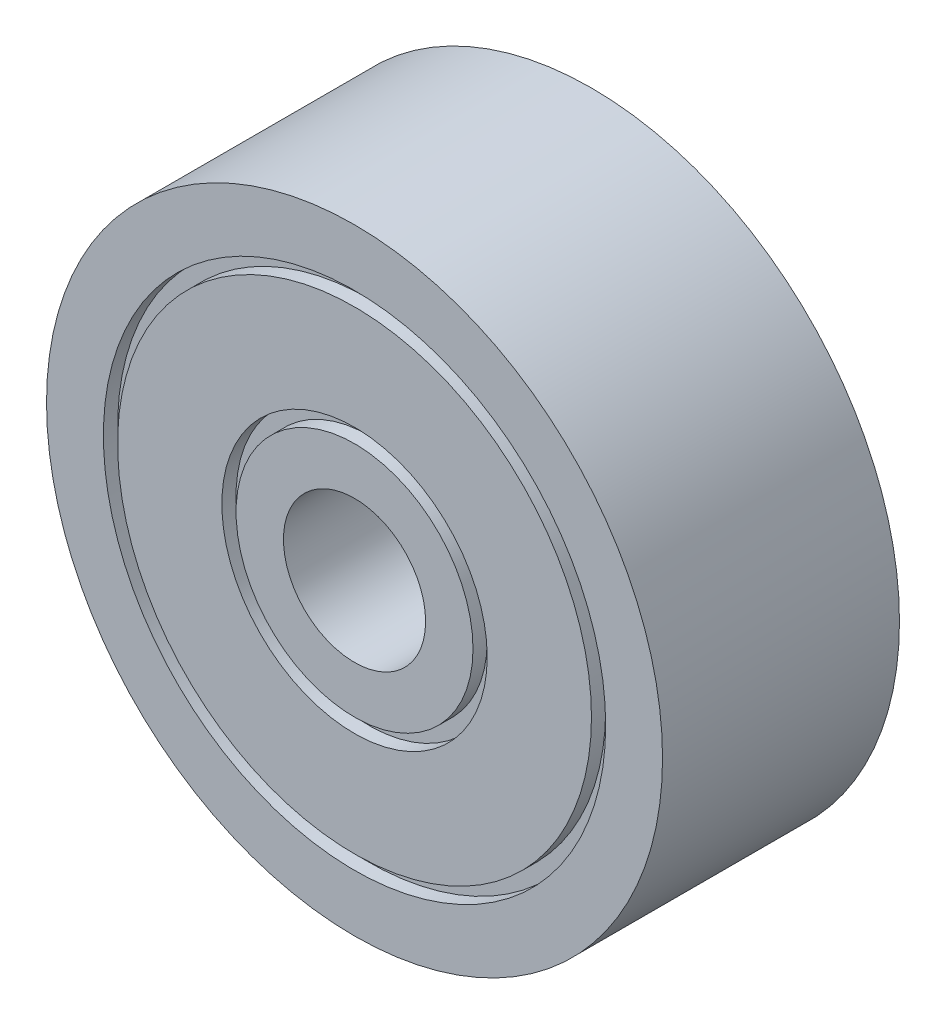
from build123d import *

# Parameters (mm, degrees)
ESQUISSE1_R        = 6.5
ESQUISSE1_R_2      = 1.5
BOSS_EXTRU_1_DEPTH = 5
ESQUISSE3_W        = 0.3
ESQUISSE3_H        = 0.3


with BuildPart() as part:
    # Esquisse1 → Boss.-Extru.1 (new body)
    with BuildSketch(Plane.XY):
        Circle(ESQUISSE1_R)
        Circle(ESQUISSE1_R_2, mode=Mode.SUBTRACT)
    extrude(amount=BOSS_EXTRU_1_DEPTH)

    # Esquisse3 → Enlèvement de matière-Révolution1 (revolve, cut)
    with BuildSketch(Plane(origin=(0, 0, 0), x_dir=(0, 0, -1), z_dir=(1, 0, 0))):
        with Locations((-4.85, 2.65)):
            Rectangle(ESQUISSE3_W, ESQUISSE3_H)
        with Locations((-0.15, 2.65)):
            Rectangle(ESQUISSE3_W, ESQUISSE3_H)
        with Locations((-4.85, 5.15)):
            Rectangle(ESQUISSE3_W, ESQUISSE3_H)
        with Locations((-0.15, 5.15)):
            Rectangle(ESQUISSE3_W, ESQUISSE3_H)
    revolve(axis=Axis((0, 0, 5.25), (0, 0, -1)), mode=Mode.SUBTRACT)


solid = part.part
